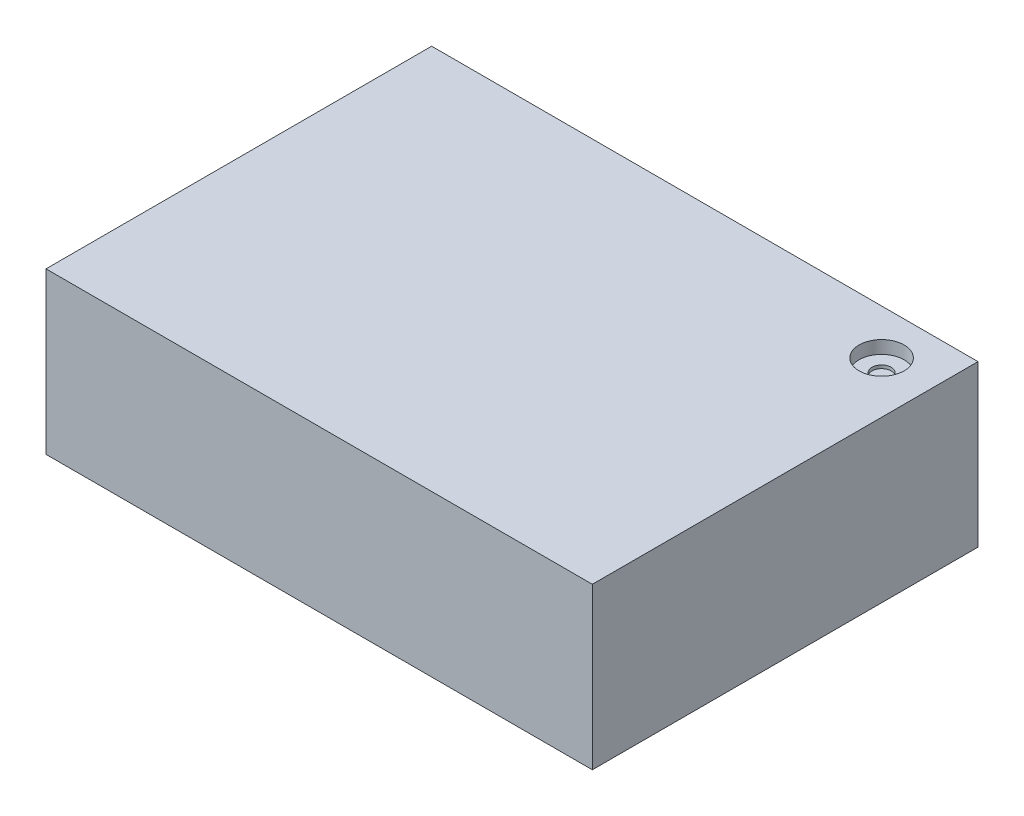
from build123d import *

# Parameters (mm, degrees)
SKETCH1_W           = 107.95
SKETCH1_H           = 76.2
BOSS_EXTRUDE1_DEPTH = 31.75
SKETCH2_W           = 73.025
SKETCH2_H           = 5.715
CUT_EXTRUDE1_DEPTH  = 104.775
SKETCH3_R           = 1.8923
CUT_EXTRUDE2_DEPTH  = 32.75
SKETCH4_R           = 4.445
CUT_EXTRUDE3_DEPTH  = 2.54


with BuildPart() as part:
    # Sketch1 → Boss-Extrude1 (new body)
    with BuildSketch(Plane(origin=(0, 0, 0), x_dir=(1, 0, 0), z_dir=(0, 1, 0))):
        Rectangle(SKETCH1_W, SKETCH1_H)
    extrude(amount=BOSS_EXTRUDE1_DEPTH)

    # Sketch2 → Cut-Extrude1 (cut)
    with BuildSketch(Plane.ZY.offset(53.975)):
        with Locations((-1.5875, 25.7175)):
            Rectangle(SKETCH2_W, SKETCH2_H)
        with Locations((-1.5875, 18.520833333)):
            Rectangle(SKETCH2_W, SKETCH2_H)
        with Locations((-1.5875, 11.324166667)):
            Rectangle(SKETCH2_W, SKETCH2_H)
        with Locations((-1.5875, 4.1275)):
            Rectangle(SKETCH2_W, SKETCH2_H)
    extrude(amount=-CUT_EXTRUDE1_DEPTH, mode=Mode.SUBTRACT)

    # Sketch3 → Cut-Extrude2 (cut, through all)
    with BuildSketch(Plane(origin=(0, 31.75, 0), x_dir=(1, 0, 0), z_dir=(0, 1, 0))):
        with Locations((43.815, 29.21)):
            Circle(SKETCH3_R)
    extrude(amount=-CUT_EXTRUDE2_DEPTH, mode=Mode.SUBTRACT)

    # Sketch4 → Cut-Extrude3 (cut)
    with BuildSketch(Plane(origin=(0, 31.75, 0), x_dir=(1, 0, 0), z_dir=(0, 1, 0))):
        with Locations((43.815, 29.21)):
            Circle(SKETCH4_R)
    extrude(amount=-CUT_EXTRUDE3_DEPTH, mode=Mode.SUBTRACT)


solid = part.part
